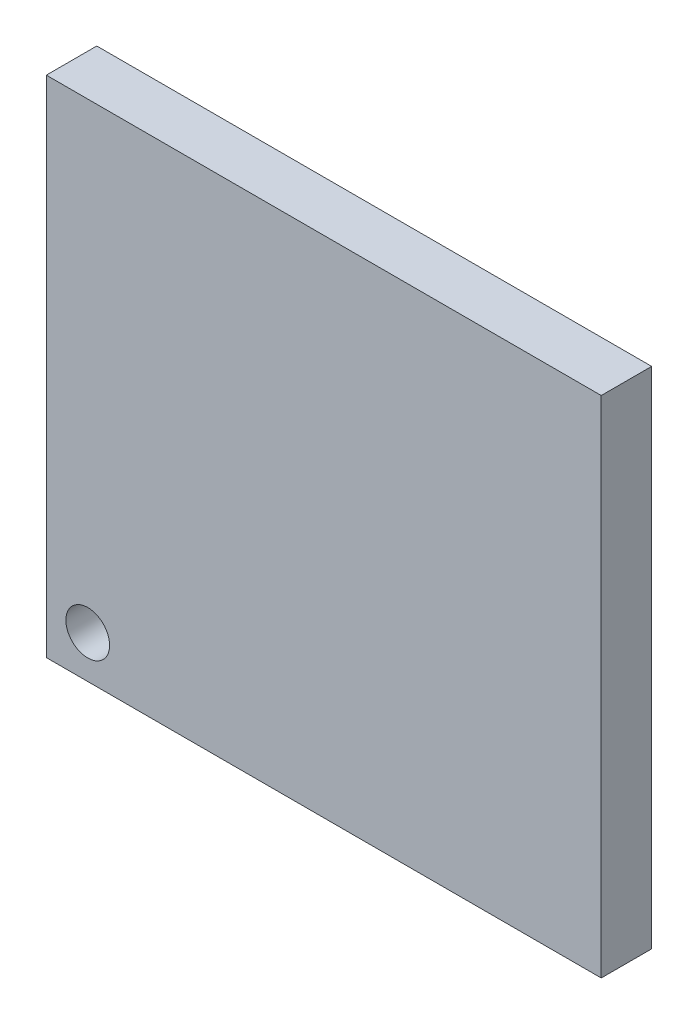
from build123d import *

# Parameters (mm, degrees)
ESQUISSE1_W            = 33
ESQUISSE1_H            = 30
BOSS_EXTRU_1_DEPTH     = 3
D_GAGEMENT_M1_61_D     = 2.6
D_GAGEMENT_M1_61_DEPTH = 50


with BuildPart() as part:
    # Esquisse1 → Boss.-Extru.1 (new body)
    with BuildSketch(Plane.XY):
        Rectangle(ESQUISSE1_W, ESQUISSE1_H)
    extrude(amount=BOSS_EXTRU_1_DEPTH)

    # Dégagement M1.61
    with Locations(Plane.XY.offset(3)):
        with Locations((-14.036286849, -12.486010391)):
            Hole(D_GAGEMENT_M1_61_D / 2, depth=D_GAGEMENT_M1_61_DEPTH)


solid = part.part
